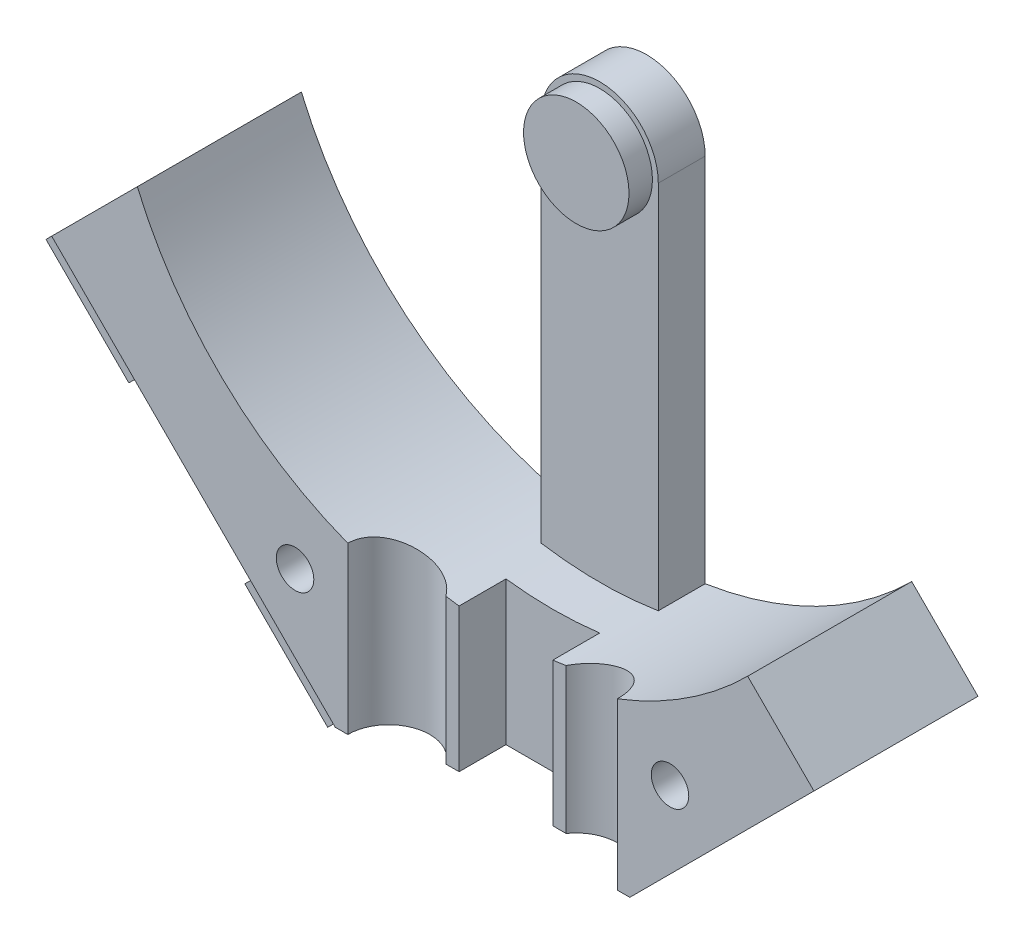
from build123d import *

# Parameters (mm, degrees)
BOSS_EXTRUDE1_DEPTH = 7
BOSS_EXTRUDE2_DEPTH = 2
BOSS_EXTRUDE3_START = 2
SKETCH3_R           = 2.25
BOSS_EXTRUDE3_DEPTH = 1
CABLE_START         = -22.5
SKETCH6_R           = 1.75
CABLE_TUBES_DEPTH   = 20
WIRE_START          = -22.5
WIRE_CANALS_DEPTH   = 8
SKETCH4_R           = 0.8
SCREW_HOLES_DEPTH   = 8.0000001
CUT_EXTRUDE2_START  = 3
CUT_EXTRUDE2_DEPTH  = 4


with BuildPart() as part:
    # Sketch1 → Boss-Extrude1 (new body)
    with BuildSketch(Plane.XY):
        with BuildLine():
            Line((14.142135624, -14.142135624), (11.313708499, -11.313708499))
            ThreePointArc((11.313708499, -11.313708499), (-3.056276198, -15.70538684), (-14.730729168, -6.245447796))
            Line((-14.730729168, -6.245447796), (-22.627416999, -14.142135627))
            Line((-22.627416999, -14.142135627), (-19.091883095, -17.677669532))
            Line((-19.091883095, -17.677669532), (-14.849242408, -13.435028845))
            Line((-14.849242408, -13.435028845), (-9.899494939, -18.384776313))
            Line((-9.899494939, -18.384776313), (-14.142135626, -22.627417))
            Line((-14.142135626, -22.627417), (-10.60660172, -26.162950906))
            Line((-10.60660172, -26.162950906), (-6.443650814, -22))
            Line((-6.443650814, -22), (6.284271247, -22))
            Line((6.284271247, -22), (14.142135624, -14.142135624))
        make_face()
    extrude(amount=BOSS_EXTRUDE1_DEPTH)

    # Sketch2 → Boss-Extrude2 (add)
    with BuildSketch(Plane.XY):
        with BuildLine():
            Line((-2.5, 0), (-2.5, -22))
            Line((-2.5, -22), (2.5, -22))
            Line((2.5, -22), (2.5, 0))
            ThreePointArc((2.5, 0), (0, 2.5), (-2.5, 0))
        make_face()
    extrude(amount=BOSS_EXTRUDE2_DEPTH)

    # Sketch3 → Boss-Extrude3 (add)
    with BuildSketch(Plane.XY.offset(BOSS_EXTRUDE3_START)):
        Circle(SKETCH3_R)
    extrude(amount=BOSS_EXTRUDE3_DEPTH)

    # Sketch6 → Cable Tubes (cut)
    with BuildSketch(Plane(origin=(0, 0, 0), x_dir=(1, 0, 0), z_dir=(0, 1, 0)).offset(CABLE_START)):
        with Locations((-4, -7)):
            Circle(SKETCH6_R)
        with Locations((4, -7)):
            Circle(SKETCH6_R)
    extrude(amount=CABLE_TUBES_DEPTH, mode=Mode.SUBTRACT)

    # Sketch7 → Wire Canals (cut)
    with BuildSketch(Plane(origin=(0, 0, 0), x_dir=(1, 0, 0), z_dir=(0, 1, 0)).offset(WIRE_START)):
        Polygon((-3, -7), (3, -7), (3, -6), (2, -6), (2, -4), (-2, -4), (-2, -6), (-3, -6), align=None)
    extrude(amount=WIRE_CANALS_DEPTH, mode=Mode.SUBTRACT)

    # Sketch4 → Screw Holes (cut, through all)
    with BuildSketch(Plane.XY):
        with Locations((-11.318596704, -23.329658004)):
            Circle(SKETCH4_R)
        with Locations((-17.682557735, -12.723056286)):
            Circle(SKETCH4_R)
        with Locations((8, -17)):
            Circle(SKETCH4_R)
        with Locations((-9.197276361, -21.20833766)):
            Circle(SKETCH4_R)
        with Locations((-8, -17)):
            Circle(SKETCH4_R)
        with Locations((-19.803878078, -14.84437663)):
            Circle(SKETCH4_R)
    extrude(amount=SCREW_HOLES_DEPTH, mode=Mode.SUBTRACT)

    # Sketch10 → Cut-Extrude2 (cut)
    with BuildSketch(Plane.XY.offset(CUT_EXTRUDE2_START)):
        Polygon((-19.091883095, -17.677669532), (-14.849242408, -13.435028845), (-18.384776312, -9.89949494), (-22.627416999, -14.142135627), align=None)
        Polygon((-14.142135626, -22.627417), (-9.899494939, -18.384776313), (-6.284271253, -22), (-6.443650814, -22), (-10.60660172, -26.162950906), align=None)
    extrude(amount=CUT_EXTRUDE2_DEPTH, mode=Mode.SUBTRACT)


solid = part.part
